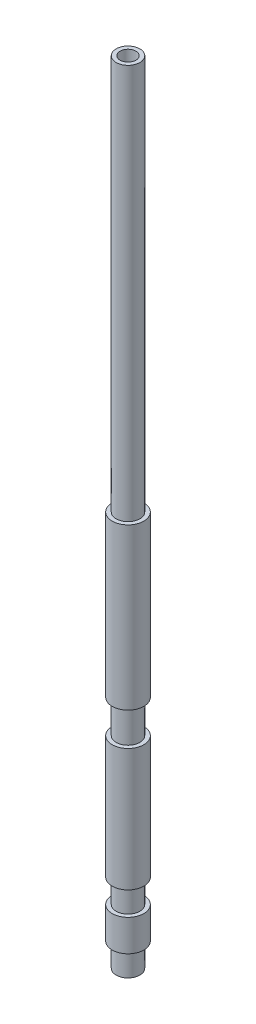
from build123d import *

# Parameters (mm, degrees)
SKETCH_1_R      = 2
SKETCH_1_R_2    = 1
EXTRUDE_1_DEPTH = 100
SKETCH_2_W      = 0.5
SKETCH_2_H      = 3
SKETCH_4_W      = 0.5
SKETCH_4_H      = 50
SKETCH_5_W      = 0.5
SKETCH_5_H      = 4.2


with BuildPart() as part:
    # Эскиз1 → Бобышка-Вытянуть1 (new body)
    with BuildSketch(Plane(origin=(0, 0, 0), x_dir=(1, 0, 0), z_dir=(0, 1, 0))):
        Circle(SKETCH_1_R)
        Circle(SKETCH_1_R_2, mode=Mode.SUBTRACT)
    extrude(amount=EXTRUDE_1_DEPTH)

    # Эскиз2 → Вырез-Повернуть1 (revolve, cut)
    with BuildSketch(Plane.XY):
        with Locations((1.75, 1.5)):
            Rectangle(SKETCH_2_W, SKETCH_2_H)
        with Locations((1.75, 8.5)):
            Rectangle(SKETCH_2_W, SKETCH_2_H)
    revolve(axis=Axis((0, 0, 0), (0, 1, 0)), mode=Mode.SUBTRACT)

    # Эскиз4 → Вырез-Повернуть2 (revolve, cut)
    with BuildSketch(Plane.XY):
        with Locations((1.75, 75)):
            Rectangle(SKETCH_4_W, SKETCH_4_H)
    revolve(axis=Axis((0, 0, 0), (0, 1, 0)), mode=Mode.SUBTRACT)

    # Эскиз5 → Вырез-Повернуть3 (revolve, cut)
    with BuildSketch(Plane.XY):
        with Locations((1.75, 27.6)):
            Rectangle(SKETCH_5_W, SKETCH_5_H)
    revolve(axis=Axis((0, 0, 0), (0, 1, 0)), mode=Mode.SUBTRACT)


solid = part.part
